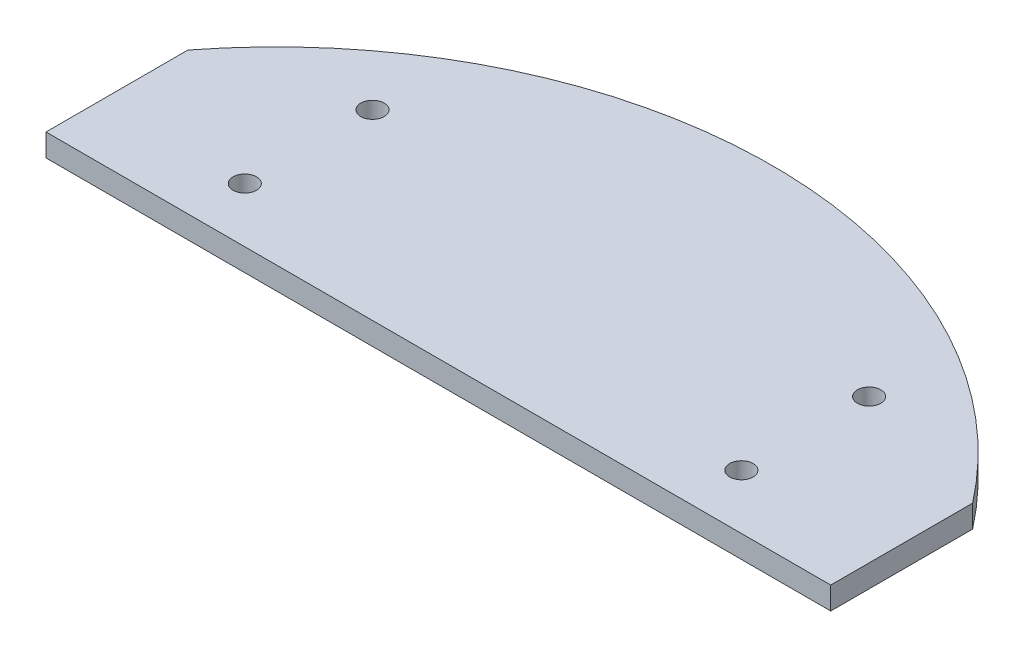
from build123d import *

# Parameters (mm, degrees)
SKETCH1_R           = 1.65
BOSS_EXTRUDE2_DEPTH = 3.175


with BuildPart() as part:
    # Sketch1 → Boss-Extrude2 (new body)
    with BuildSketch(Plane(origin=(0, 0, 0), x_dir=(1, 0, 0), z_dir=(0, 1, 0))):
        with BuildLine():
            Line((-55.306734792, 42.908799641), (-55.306734792, 22.908799641))
            Line((-55.306734792, 22.908799641), (55.306734792, 22.908799641))
            Line((55.306734792, 22.908799641), (55.306734792, 42.908799641))
            ThreePointArc((55.306734792, 42.908799641), (0, 70), (-55.306734792, 42.908799641))
        make_face()
        with Locations((35, 48.621778265)):
            Circle(SKETCH1_R, mode=Mode.SUBTRACT)
        with Locations((35, 30.621778265)):
            Circle(SKETCH1_R, mode=Mode.SUBTRACT)
        with Locations((-35, 30.621778265)):
            Circle(SKETCH1_R, mode=Mode.SUBTRACT)
        with Locations((-35, 48.621778265)):
            Circle(SKETCH1_R, mode=Mode.SUBTRACT)
    extrude(amount=BOSS_EXTRUDE2_DEPTH)


solid = part.part
